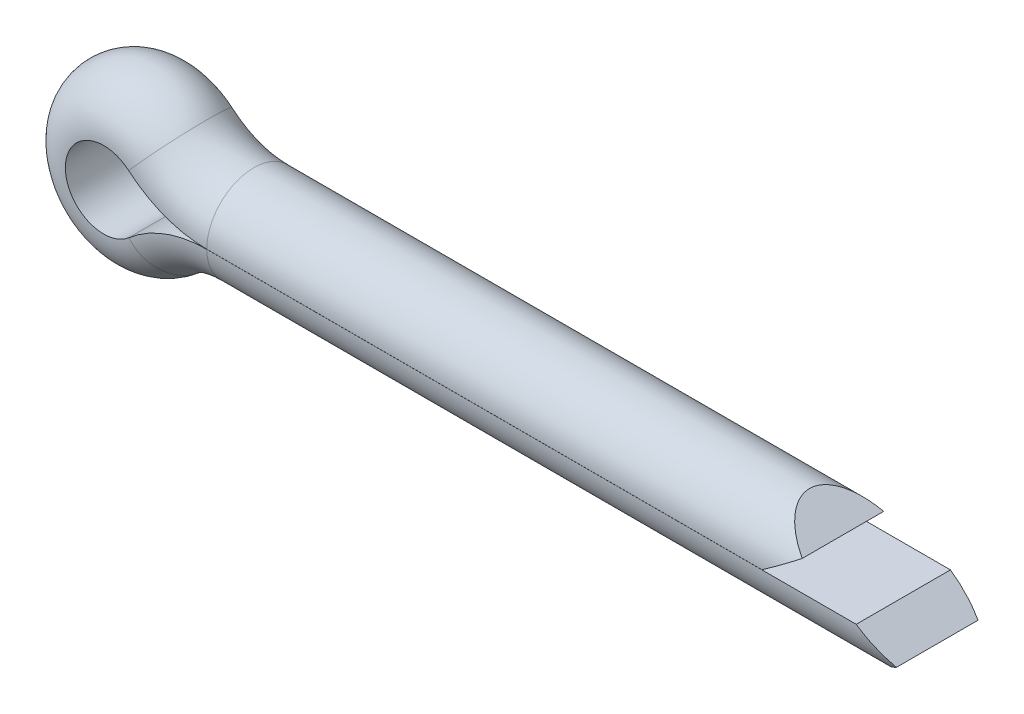
from build123d import *

# Parameters (mm, degrees)
CONECUT_DEPTH      = 2.59999885
CONECUT_DEPTH_BACK = 2.59999885


with BuildPart() as part:
    # Body: sweep along a path in 草图2
    with BuildLine(Plane.XY) as body_path:
        Line((20, 1.6), (0, 1.6))
        ThreePointArc((0, 1.6), (-0.857074534, 1.7540301), (-1.606886657, 2.196843615))
        ThreePointArc((-1.606886657, 2.196843615), (-6.4, 0), (-1.606886657, -2.196843615))
        ThreePointArc((-1.606886657, -2.196843615), (-0.857074534, -1.7540301), (0, -1.6))
        Line((0, -1.6), (23.2, -1.6))
    # 草图1 → Body (sweep)
    with BuildSketch(Plane(origin=(20, 0, 0), x_dir=(0, 0, -1), z_dir=(1, 0, 0))):
        with BuildLine():
            Line((-1.59999875, 0.002), (1.59999875, 0.002))
            ThreePointArc((1.59999875, 0.002), (0, 1.6), (-1.59999875, 0.002))
        make_face()
    sweep(path=body_path.line)

    # 草图3 → ConeCut (cut, two sides)
    with BuildSketch(Plane.XY) as conecut_sk:
        Polygon((20, 0.801), (18.853141685, 1.61), (23.21, 1.61), (23.21, -1.61), (22.053141685, -1.61), (23.2, -0.801), (22.047540024, 0), (18.847540024, 0), align=None)
    extrude(amount=CONECUT_DEPTH, mode=Mode.SUBTRACT)
    extrude(conecut_sk.sketch, amount=-CONECUT_DEPTH_BACK, mode=Mode.SUBTRACT)


solid = part.part
